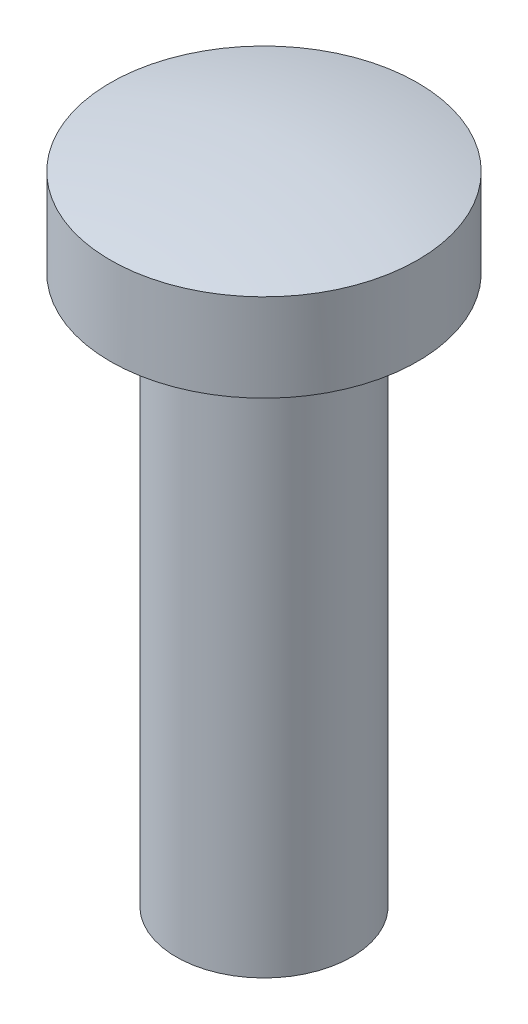
from build123d import *


with BuildPart() as part:
    # Skizze1 → Rotation1 (revolve)
    with BuildSketch(Plane.XY, mode=Mode.PRIVATE) as rotation1_sk:
        with BuildLine():
            Line((0, 0), (0, 29.83286778))
            ThreePointArc((0, 29.83286778), (3.524686821, 29.6239191), (7, 29))
            Line((7, 29), (7, 25))
            Line((7, 25), (4, 25))
            Line((4, 25), (4, 0))
            Line((4, 0), (0, 0))
        make_face()
    revolve(rotation1_sk.sketch.rotate(Axis((0, 0, 0), (0, 1, 0)), 90), axis=Axis((0, 0, 0), (0, 1, 0)))  # turned: the seam where the file's is


solid = part.part
